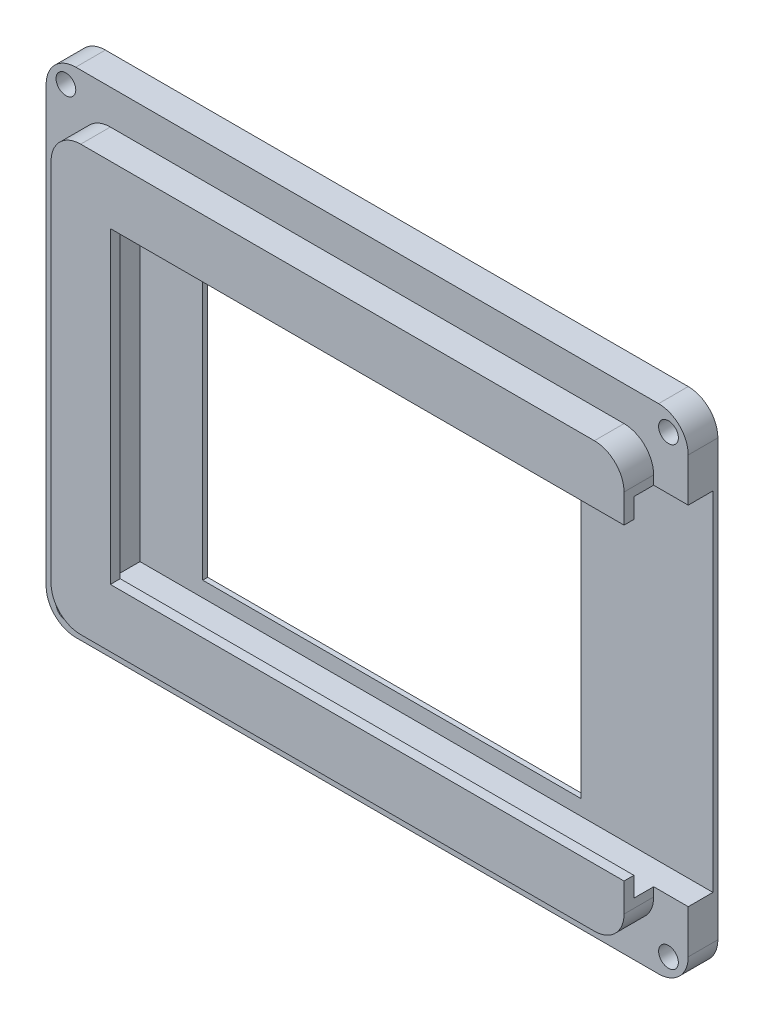
from build123d import *

# Parameters (mm, degrees)
SKIZZE1_W                       = 65
SKIZZE1_H                       = 50
AUFSATZ_LINEAR_AUSTRAGEN1_DEPTH = 3
SKIZZE2_W                       = 58
SKIZZE2_H                       = 43
AUFSATZ_LINEAR_AUSTRAGEN2_DEPTH = 3
SKIZZE7_W                       = 35.2
SKIZZE7_H                       = 4.5
SCHNITT_LINEAR_AUSTRAGEN2_DEPTH = 58
SKIZZE9_W                       = 1
SKIZZE9_H                       = 31.2
SCHNITT_LINEAR_AUSTRAGEN3_DEPTH = 52
SCHNITT_LINEAR_AUSTRAGEN4_REACH = 8
SKIZZE10_W                      = 38.3
SKIZZE10_H                      = 32.1
VERRUNDUNG2_R                   = 3
SKIZZE11_R                      = 1
SCHNITT_LINEAR_AUSTRAGEN5_DEPTH = 7
FASE1_SIZE                      = 0.5


with BuildPart() as part:
    # Skizze1 → Aufsatz-Linear austragen1 (new body)
    with BuildSketch(Plane.XY):
        with Locations((32.5, -25)):
            Rectangle(SKIZZE1_W, SKIZZE1_H)
    extrude(amount=AUFSATZ_LINEAR_AUSTRAGEN1_DEPTH)

    # Skizze2 → Aufsatz-Linear austragen2 (add)
    with BuildSketch(Plane.XY.offset(3)):
        with Locations((32.5, -25)):
            Rectangle(SKIZZE2_W, SKIZZE2_H)
    extrude(amount=AUFSATZ_LINEAR_AUSTRAGEN2_DEPTH)

    # Skizze7 → Schnitt-Linear austragen2 (cut)
    with BuildSketch(Plane(origin=(65, -65, 0), x_dir=(0, 1, 0), z_dir=(-1, 0, 0))):
        with Locations((40, -2.75)):
            Rectangle(SKIZZE7_W, SKIZZE7_H)
    extrude(amount=SCHNITT_LINEAR_AUSTRAGEN2_DEPTH, mode=Mode.SUBTRACT)

    # Skizze9 → Schnitt-Linear austragen3 (cut)
    with BuildSketch(Plane(origin=(61.5, 0, 0), x_dir=(0, 0, -1), z_dir=(1, 0, 0))):
        with Locations((-5.5, -25)):
            Rectangle(SKIZZE9_W, SKIZZE9_H)
    extrude(amount=-SCHNITT_LINEAR_AUSTRAGEN3_DEPTH, mode=Mode.SUBTRACT)

    # Skizze10 → Schnitt-Linear austragen4 (cut, up to next)
    with BuildSketch(Plane(origin=(0, 0, 0), x_dir=(-1, 0, 0), z_dir=(0, 0, -1)), mode=Mode.PRIVATE) as schnitt_linear_austragen4_sk1:
        with Locations((-32.5, -25)):
            Rectangle(SKIZZE10_W, SKIZZE10_H)
    schnitt_linear_austragen4_tool1 = extrude(schnitt_linear_austragen4_sk1.sketch, amount=-SCHNITT_LINEAR_AUSTRAGEN4_REACH, mode=Mode.PRIVATE) & part.part
    add(schnitt_linear_austragen4_tool1.solids().sort_by_distance((32.5, -25, 0))[0], mode=Mode.SUBTRACT)

    # Verrundung2
    verrundung2_edges = [part.edges().sort_by_distance(p)[0] for p in [
        (61.5, -3.5, 4.5),
        (3.5, -3.5, 4.5),
        (3.5, -46.5, 4.5),
        (61.5, -46.5, 4.5),
        (0, 0, 1.5),
        (65, 0, 1.5),
        (65, -50, 1.5),
        (0, -50, 1.5),
    ]]
    fillet(verrundung2_edges, radius=VERRUNDUNG2_R)

    # Skizze11 → Schnitt-Linear austragen5 (cut, through all)
    with BuildSketch(Plane(origin=(0, 0, 0), x_dir=(-1, 0, 0), z_dir=(0, 0, -1))):
        with Locations((-63, -2)):
            Circle(SKIZZE11_R)
        with Locations((-2, -2)):
            Circle(SKIZZE11_R)
        with Locations((-2, -48)):
            Circle(SKIZZE11_R)
        with Locations((-63, -48)):
            Circle(SKIZZE11_R)
    extrude(amount=-SCHNITT_LINEAR_AUSTRAGEN5_DEPTH, mode=Mode.SUBTRACT)

    # Fase1
    fase1_edges = [part.edges().sort_by_distance(p)[0] for p in [
        (64, -2, 0),
        (3, -2, 0),
        (3, -48, 0),
        (64, -48, 0),
    ]]
    chamfer(fase1_edges, length=FASE1_SIZE)


solid = part.part
